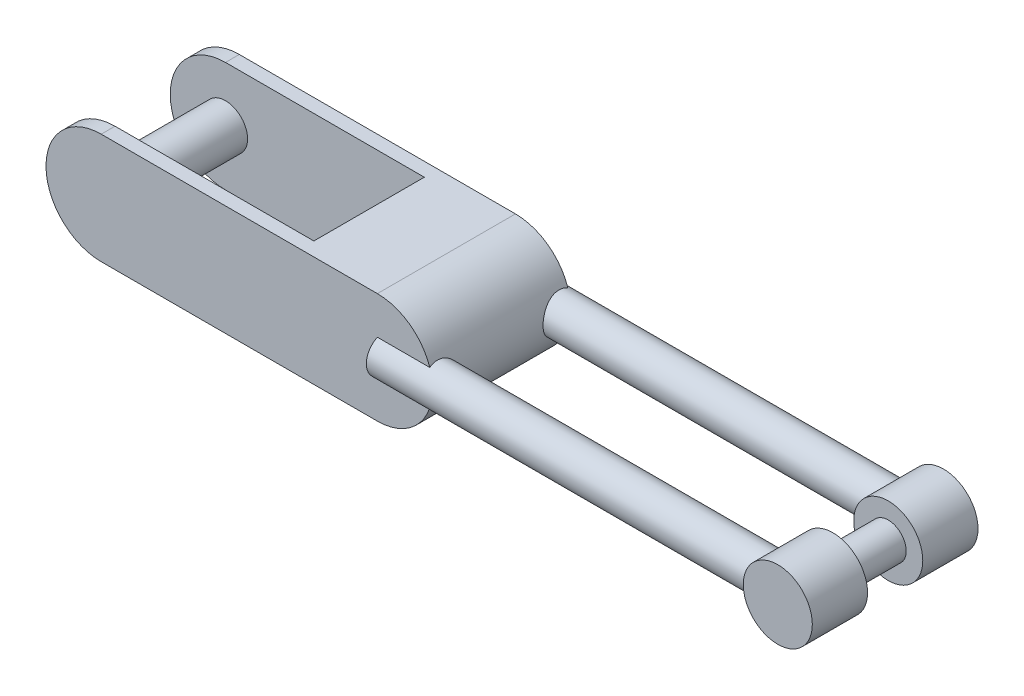
from build123d import *

# Parameters (mm, degrees)
EXTRUDE1_DEPTH     = 12.5
SKETCH2_W          = 50
SKETCH2_H          = 20
CUT_EXTRUDE1_DEPTH = 21
SKETCH3_R          = 3.5
EXTRUDE2_DEPTH     = 70
SKETCH4_R          = 6.25
EXTRUDE3_DEPTH     = 15
SKETCH7_R          = 6.25
SKETCH7_R_2        = 3.25
EXTRUDE6_DEPTH     = 5
SKETCH6_R          = 4
EXTRUDE5_DEPTH     = 20


with BuildPart() as part:
    # Sketch1 → Extrude1 (new body, symmetric)
    with BuildSketch(Plane.XY):
        with BuildLine():
            Line((50, 10), (0, 10))
            ThreePointArc((0, 10), (-10, 0), (0, -10))
            Line((0, -10), (50, -10))
            ThreePointArc((50, -10), (60, 0), (50, 10))
        make_face()
    extrude(amount=EXTRUDE1_DEPTH, both=True)

    # Sketch2 → Cut-Extrude1 (cut, through all)
    with BuildSketch(Plane(origin=(0, 10, 0), x_dir=(-1, 0, 0), z_dir=(0, 1, 0))):
        with Locations((-11, 0)):
            Rectangle(SKETCH2_W, SKETCH2_H)
    extrude(amount=-CUT_EXTRUDE1_DEPTH, mode=Mode.SUBTRACT)

    # Sketch3 → Extrude2 (add)
    with BuildSketch(Plane.YZ.offset(50)):
        with Locations((0, 11)):
            Circle(SKETCH3_R)
    extrude2 = extrude(amount=EXTRUDE2_DEPTH)

    # Mirror1: Extrude2 across plane
    add(extrude2.mirror(Plane.XY))

    # Sketch4 → Extrude3 (add, symmetric)
    with BuildSketch(Plane.XY):
        with Locations((125, 0)):
            Circle(SKETCH4_R)
    extrude(amount=EXTRUDE3_DEPTH, both=True)

    # Sketch7 → Extrude6 (cut, symmetric)
    with BuildSketch(Plane.XY):
        with Locations((125, 0)):
            Circle(SKETCH7_R)
        with Locations((125, 0)):
            Circle(SKETCH7_R_2, mode=Mode.SUBTRACT)
    extrude(amount=EXTRUDE6_DEPTH, both=True, mode=Mode.SUBTRACT)

    # Sketch6 → Extrude5 (add)
    with BuildSketch(Plane.XY.offset(-10)):
        Circle(SKETCH6_R)
    extrude(amount=EXTRUDE5_DEPTH)


solid = part.part
